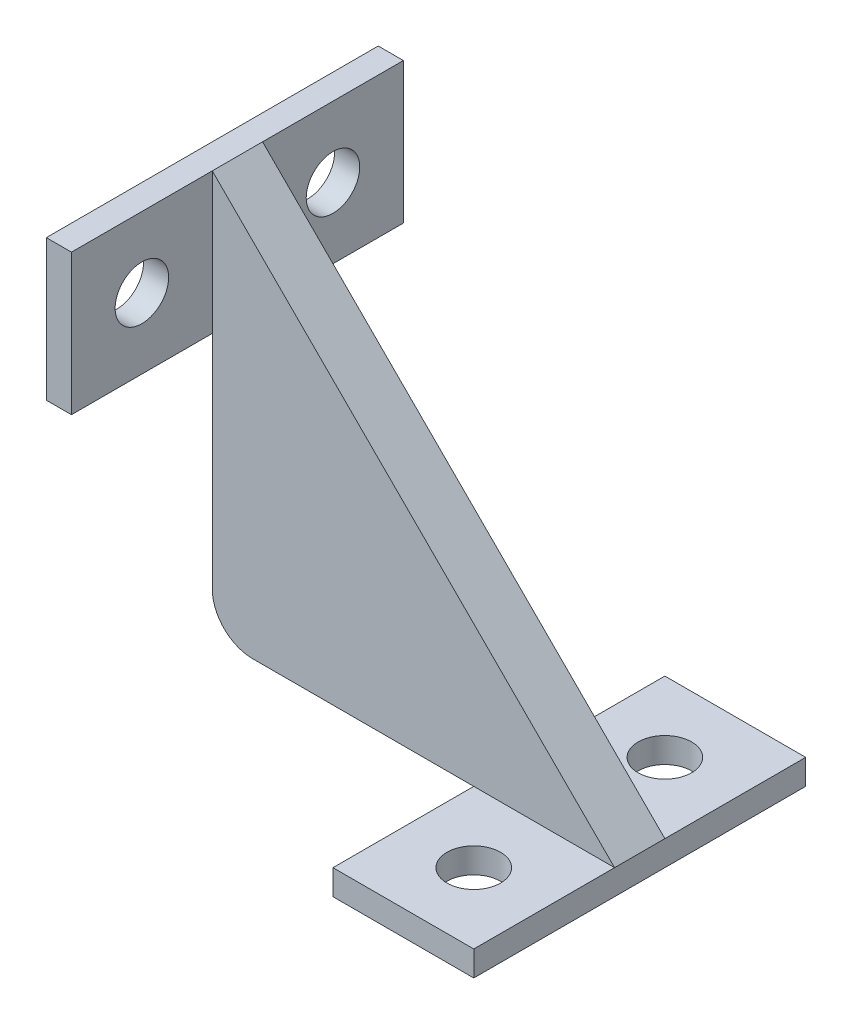
from build123d import *

# Parameters (mm, degrees)
BOSS_EXTRUDE1_DEPTH = 6.35
SKETCH2_W           = 41.91
SKETCH2_H           = 17.78
BOSS_EXTRUDE2_DEPTH = 3.175
SKETCH3_W           = 17.78
SKETCH3_H           = 41.91
BOSS_EXTRUDE3_DEPTH = 3.175
SKETCH4_R           = 3.3782
CUT_EXTRUDE1_DEPTH  = 3.175
SKETCH5_R           = 3.3782
CUT_EXTRUDE2_DEPTH  = 3.175


with BuildPart() as part:
    # Sketch1 → Boss-Extrude1 (new body)
    with BuildSketch(Plane.XY):
        with BuildLine():
            Line((0, 5.08), (0, 50.8))
            Line((0, 50.8), (50.8, 0))
            Line((50.8, 0), (5.08, 0))
            ThreePointArc((5.08, 0), (1.487897552, 1.487897552), (0, 5.08))
        make_face()
    extrude(amount=BOSS_EXTRUDE1_DEPTH)

    # Sketch2 → Boss-Extrude2 (add)
    with BuildSketch(Plane.ZY):
        with Locations((3.175, 41.91)):
            Rectangle(SKETCH2_W, SKETCH2_H)
    extrude(amount=BOSS_EXTRUDE2_DEPTH)

    # Sketch3 → Boss-Extrude3 (add)
    with BuildSketch(Plane.XZ):
        with Locations((41.91, 3.175)):
            Rectangle(SKETCH3_W, SKETCH3_H)
    extrude(amount=BOSS_EXTRUDE3_DEPTH)

    # Sketch4 → Cut-Extrude1 (cut)
    with BuildSketch(Plane(origin=(0, 0, 0), x_dir=(1, 0, 0), z_dir=(0, 1, 0))):
        with Locations((41.91, 8.89)):
            Circle(SKETCH4_R)
        with Locations((41.91, -15.24)):
            Circle(SKETCH4_R)
    extrude(amount=-CUT_EXTRUDE1_DEPTH, mode=Mode.SUBTRACT)

    # Sketch5 → Cut-Extrude2 (cut)
    with BuildSketch(Plane(origin=(0, 0, 0), x_dir=(0, 0, -1), z_dir=(1, 0, 0))):
        with Locations((-15.24, 41.91)):
            Circle(SKETCH5_R)
        with Locations((8.89, 41.91)):
            Circle(SKETCH5_R)
    extrude(amount=-CUT_EXTRUDE2_DEPTH, mode=Mode.SUBTRACT)


solid = part.part
